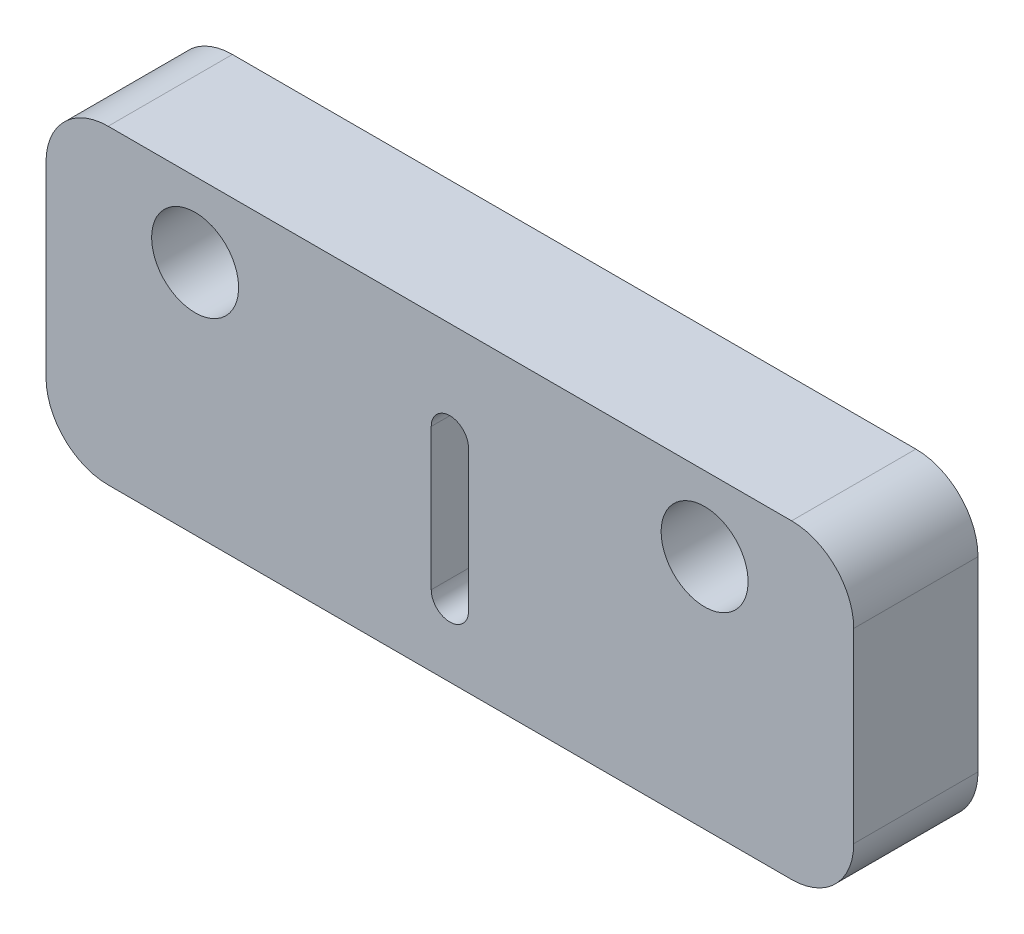
from build123d import *

# Parameters (mm, degrees)
SKETCH1_W           = 65
SKETCH1_H           = 10
BOSS_EXTRUDE1_DEPTH = 25
SKETCH2_R           = 3.5
CUT_EXTRUDE1_DEPTH  = 25
FILLET1_R           = 5


with BuildPart() as part:
    # Sketch1 → Boss-Extrude1 (new body)
    with BuildSketch(Plane(origin=(0, 0, 0), x_dir=(1, 0, 0), z_dir=(0, 1, 0))):
        with Locations((2.312734082, 5.346441948)):
            Rectangle(SKETCH1_W, SKETCH1_H)
    extrude(amount=BOSS_EXTRUDE1_DEPTH)

    # Sketch2 → Cut-Extrude1 (cut)
    with BuildSketch(Plane(origin=(0, 0, -10.346441948), x_dir=(-1, 0, 0), z_dir=(0, 0, -1))):
        with Locations((18.187265918, 19)):
            Circle(SKETCH2_R)
        with BuildLine():
            Line((-3.812734082, 17.077006126), (-3.812734082, 5.696172333))
            ThreePointArc((-3.812734082, 5.696172333), (-2.312734082, 4.196172333), (-0.812734082, 5.696172333))
            Line((-0.812734082, 5.696172333), (-0.812734082, 17.077006126))
            ThreePointArc((-0.812734082, 17.077006126), (-2.312734082, 18.577006126), (-3.812734082, 17.077006126))
        make_face()
        with Locations((-22.812734082, 19)):
            Circle(SKETCH2_R)
    extrude(amount=-CUT_EXTRUDE1_DEPTH, mode=Mode.SUBTRACT)

    # Fillet1
    fillet1_edges = [part.edges().sort_by_distance(p)[0] for p in [
        (34.812734082, 25, -5.346441948),
        (-30.187265918, 25, -5.346441948),
        (34.812734082, 0, -5.346441948),
        (-30.187265918, 0, -5.346441948),
    ]]
    fillet(fillet1_edges, radius=FILLET1_R)


solid = part.part
